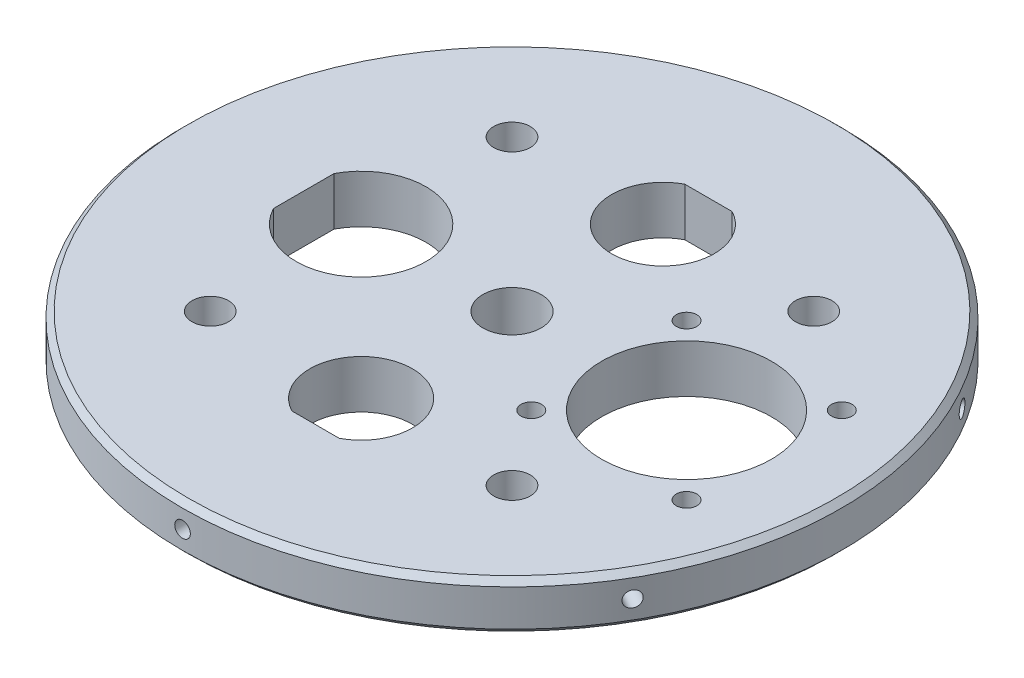
from build123d import *

# Parameters (mm, degrees)
SKETCH2_R           = 57.15
BOSS_EXTRUDE1_DEPTH = 8.35
CUT_EXTRUDE1_REACH  = 10.35
SKETCH6_R           = 3.175
SKETCH7_R           = 14.732
SKETCH7_R_2         = 1.778
CUT_EXTRUDE2_DEPTH  = 9.35
SKETCH8_R           = 5.042
CUT_EXTRUDE3_DEPTH  = 9.35
CIRPATTERN1_COUNT   = 6
CHAMFER1_SIZE       = 1


with BuildPart() as part:
    # Sketch2 → Boss-Extrude1 (new body)
    with BuildSketch(Plane(origin=(0, 0, 0), x_dir=(1, 0, 0), z_dir=(0, 1, 0))):
        Circle(SKETCH2_R)
    extrude(amount=BOSS_EXTRUDE1_DEPTH)

    # Sketch6 → Cut-Extrude1 (cut, up to next)
    with BuildSketch(Plane(origin=(0, 8.35, 0), x_dir=(1, 0, 0), z_dir=(0, 1, 0)), mode=Mode.PRIVATE) as cut_extrude1_sk1:
        with Locations((-26.1629, -26.1629)):
            Circle(SKETCH6_R)
    cut_extrude1_tool1 = extrude(cut_extrude1_sk1.sketch, amount=-CUT_EXTRUDE1_REACH, mode=Mode.PRIVATE) & part.part
    add(cut_extrude1_tool1.solids().sort_by_distance((-26.1629, 8.35, 26.1629))[0], mode=Mode.SUBTRACT)
    # Sketch6 → Cut-Extrude1 (cut, up to next)
    with BuildSketch(Plane(origin=(0, 8.35, 0), x_dir=(1, 0, 0), z_dir=(0, 1, 0)), mode=Mode.PRIVATE) as cut_extrude1_sk2:
        with Locations((26.1629, -26.1629)):
            Circle(SKETCH6_R)
    cut_extrude1_tool2 = extrude(cut_extrude1_sk2.sketch, amount=-CUT_EXTRUDE1_REACH, mode=Mode.PRIVATE) & part.part
    add(cut_extrude1_tool2.solids().sort_by_distance((26.1629, 8.35, 26.1629))[0], mode=Mode.SUBTRACT)
    # Sketch6 → Cut-Extrude1 (cut, up to next)
    with BuildSketch(Plane(origin=(0, 8.35, 0), x_dir=(1, 0, 0), z_dir=(0, 1, 0)), mode=Mode.PRIVATE) as cut_extrude1_sk3:
        with Locations((-26.1629, 26.163103615)):
            Circle(SKETCH6_R)
    cut_extrude1_tool3 = extrude(cut_extrude1_sk3.sketch, amount=-CUT_EXTRUDE1_REACH, mode=Mode.PRIVATE) & part.part
    add(cut_extrude1_tool3.solids().sort_by_distance((-26.1629, 8.35, -26.163104))[0], mode=Mode.SUBTRACT)
    # Sketch6 → Cut-Extrude1 (cut, up to next)
    with BuildSketch(Plane(origin=(0, 8.35, 0), x_dir=(1, 0, 0), z_dir=(0, 1, 0)), mode=Mode.PRIVATE) as cut_extrude1_sk4:
        with Locations((26.1629, 26.163103615)):
            Circle(SKETCH6_R)
    cut_extrude1_tool4 = extrude(cut_extrude1_sk4.sketch, amount=-CUT_EXTRUDE1_REACH, mode=Mode.PRIVATE) & part.part
    add(cut_extrude1_tool4.solids().sort_by_distance((26.1629, 8.35, -26.163104))[0], mode=Mode.SUBTRACT)

    # Sketch7 → Cut-Extrude2 (cut, through all)
    with BuildSketch(Plane(origin=(0, 8.35, 0), x_dir=(1, 0, 0), z_dir=(0, 1, 0))):
        with Locations((30, 0.269903496)):
            Circle(SKETCH7_R)
        with Locations((16.54, -13.194096504)):
            Circle(SKETCH7_R_2)
        with Locations((16.54, 13.729903496)):
            Circle(SKETCH7_R_2)
        with Locations((43.46, 13.729903496)):
            Circle(SKETCH7_R_2)
        with Locations((43.46, -13.194096504)):
            Circle(SKETCH7_R_2)
    extrude(amount=-CUT_EXTRUDE2_DEPTH, mode=Mode.SUBTRACT)

    # Sketch8 → Cut-Extrude3 (cut, through all)
    with BuildSketch(Plane(origin=(0, 8.35, 0), x_dir=(1, 0, 0), z_dir=(0, 1, 0))):
        Circle(SKETCH8_R)
        with BuildLine():
            Line((4.098780306, 34.063103615), (-4.098780306, 34.063103615))
            ThreePointArc((-4.098780306, 34.063103615), (0, 17.263103615), (4.098780306, 34.063103615))
        make_face()
        with BuildLine():
            Line((4.098780306, -34.0629), (-4.098780306, -34.0629))
            ThreePointArc((-4.098780306, -34.0629), (0, -17.2629), (4.098780306, -34.0629))
        make_face()
        with BuildLine():
            Line((-36.1129, 5.249761899), (-36.1129, -5.249761899))
            ThreePointArc((-36.1129, -5.249761899), (-14.9129, 0), (-36.1129, 5.249761899))
        make_face()
    extrude(amount=-CUT_EXTRUDE3_DEPTH, mode=Mode.SUBTRACT)

    # Sketch16 → #6-32 Tapped Hole1 (revolve, cut)
    with BuildSketch(Plane(origin=(0, 4.175, -57.15), x_dir=(0, 1, 0), z_dir=(1, 0, 0))):
        Polygon((0, 0), (0, 13.81269403), (1.35255, 13), (1.35255, 0), align=None)
    f_6_32_tapped_hole1 = revolve(axis=Axis((0, 4.175, -63.5), (0, 0, 1)), mode=Mode.SUBTRACT)

    # CirPattern1: #6-32 Tapped Hole1 ×6 about axis
    cirpattern1_axis = Axis((0, 0, 0), (0, 1, 0))
    for i in range(1, CIRPATTERN1_COUNT):
        add(f_6_32_tapped_hole1.rotate(cirpattern1_axis, i * 360 / CIRPATTERN1_COUNT), mode=Mode.SUBTRACT)

    # Chamfer1
    chamfer1_edges = [part.edges().sort_by_distance(p)[0] for p in [
        (-57.15, 0, 0),
        (-57.15, 8.35, 0),
    ]]
    chamfer(chamfer1_edges, length=CHAMFER1_SIZE)


solid = part.part
